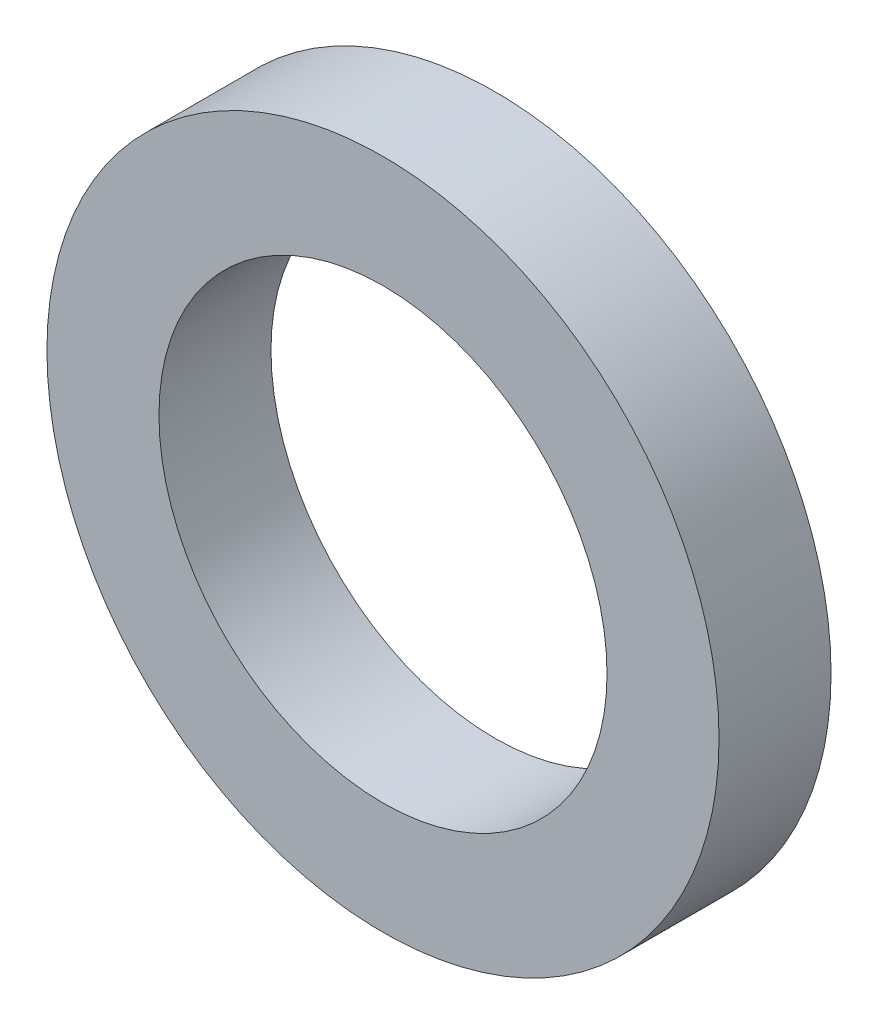
from build123d import *

# Parameters (mm, degrees)
SKETCH1_R           = 15
SKETCH1_R_2         = 10
BOSS_EXTRUDE1_DEPTH = 5


with BuildPart() as part:
    # Sketch1 → Boss-Extrude1 (new body)
    with BuildSketch(Plane.XY):
        Circle(SKETCH1_R)
        Circle(SKETCH1_R_2, mode=Mode.SUBTRACT)
    extrude(amount=BOSS_EXTRUDE1_DEPTH)


solid = part.part
